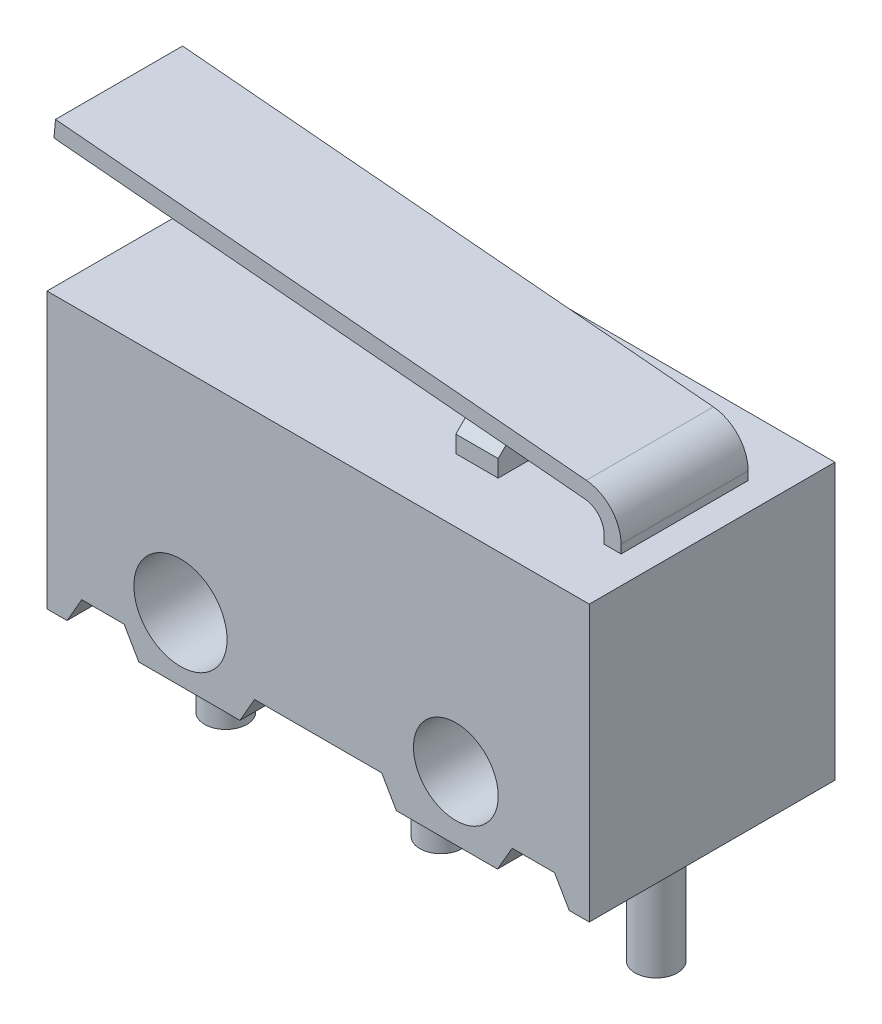
from build123d import *

# Parameters (mm, degrees)
SKETCH1_W           = 12.8
SKETCH1_H           = 6.5
SKETCH1_R           = 1.1
SKETCH1_R_2         = 1
BOSS_EXTRUDE1_DEPTH = 2.9
CUT_EXTRUDE4_DEPTH  = 6.8
SKETCH3_W           = 1
SKETCH3_H           = 0.9
BOSS_EXTRUDE2_DEPTH = 1.4
CHAMFER1_SIZE       = 0.5
SKETCH13_R          = 0.5
BOSS_EXTRUDE9_DEPTH = 3.5
BOSS_EXTRUDE8_DEPTH = 1.5


with BuildPart() as part:
    # Sketch1 → Boss-Extrude1 (new body, symmetric)
    with BuildSketch(Plane.XY):
        with Locations((0, 1.75)):
            Rectangle(SKETCH1_W, SKETCH1_H)
        with Locations((-3.25, 0)):
            Circle(SKETCH1_R, mode=Mode.SUBTRACT)
        with Locations((3.25, 0)):
            Circle(SKETCH1_R_2, mode=Mode.SUBTRACT)
    extrude(amount=BOSS_EXTRUDE1_DEPTH, both=True)

    # Sketch12 → Cut-Extrude4 (cut, through all)
    with BuildSketch(Plane.XY.offset(2.9)):
        Polygon((-1.846410162, -1.5), (-1.5, -0.9), (1.5, -0.9), (1.846410162, -1.5), align=None)
        Polygon((-5.926410162, -1.5), (-5.58, -0.9), (-4.58, -0.9), (-4.233589838, -1.5), align=None)
        Polygon((4.233589838, -1.5), (5.926410162, -1.5), (5.58, -0.9), (4.58, -0.9), align=None)
    extrude(amount=-CUT_EXTRUDE4_DEPTH, mode=Mode.SUBTRACT)

    # Sketch3 → Boss-Extrude2 (add, symmetric)
    with BuildSketch(Plane.XY):
        with Locations((2.25, 5.45)):
            Rectangle(SKETCH3_W, SKETCH3_H)
    extrude(amount=BOSS_EXTRUDE2_DEPTH, both=True)

    # Chamfer1
    chamfer1_edges = [part.edges().sort_by_distance(p)[0] for p in [
        (2.25, 5.9, -1.4),
        (2.25, 5.9, 1.4),
    ]]
    chamfer(chamfer1_edges, length=CHAMFER1_SIZE)

    # Sketch13 → Boss-Extrude9 (add)
    with BuildSketch(Plane.XZ.offset(0.9)):
        Circle(SKETCH13_R)
        with Locations((-5.08, 0)):
            Circle(SKETCH13_R)
        with Locations((5.08, 0)):
            Circle(SKETCH13_R)
    extrude(amount=BOSS_EXTRUDE9_DEPTH)


with BuildPart() as body_2:
    # Sketch11 → Boss-Extrude8 (new body, symmetric)
    with BuildSketch(Plane.XY):
        with BuildLine():
            Line((-7.635359223, 6.81), (4.894376977, 5.698042615))
            ThreePointArc((4.894376977, 5.698042615), (5.219027182, 5.537565168), (5.350177949, 5.2))
            Line((5.350177949, 5.2), (5.350177949, 5))
            Line((5.350177949, 5), (5.750177949, 5))
            Line((5.750177949, 5), (5.750177949, 5.2))
            ThreePointArc((5.750177949, 5.2), (5.514106569, 5.807617303), (4.929736199, 6.096476706))
            Line((4.929736199, 6.096476706), (-7.6, 7.208434092))
            Line((-7.6, 7.208434092), (-7.635359223, 6.81))
        make_face()
    extrude(amount=BOSS_EXTRUDE8_DEPTH, both=True)


solid = Compound([part.part, body_2.part])
